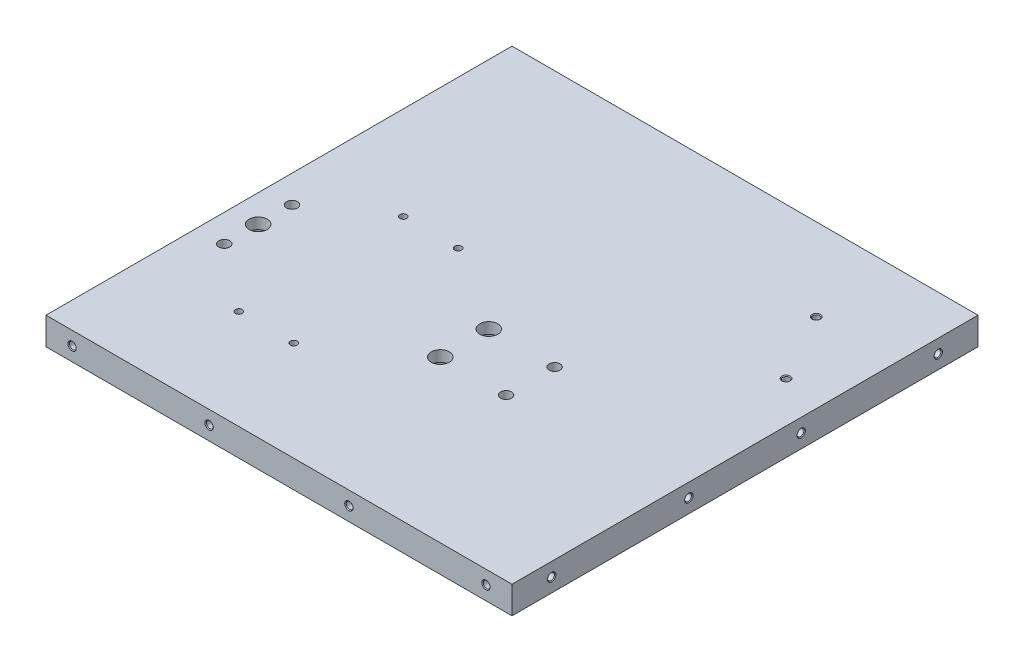
from build123d import *

# Parameters (mm, degrees)
SKETCH1_W                       = 170
SKETCH1_H                       = 170
BOSS_EXTRUDE1_DEPTH             = 10
F_4_0MM_DOWEL_HOLE1_D           = 4
F_4_0MM_DOWEL_HOLE1_DEPTH       = 5.2
F_4_0MM_DOWEL_HOLE1_TIP         = 1.201721238
CBORE_FOR_M6_SHCS1_D            = 6.6
CBORE_FOR_M6_SHCS1_DEPTH        = 10
CBORE_FOR_M6_SHCS1_CBORE_D      = 11
CBORE_FOR_M6_SHCS1_CBORE_DEPTH  = 6
M3X0_5_TAPPED_HOLE1_D           = 2.5
M3X0_5_TAPPED_HOLE1_DEPTH       = 7.5
M3X0_5_TAPPED_HOLE1_TIP         = 0.751075774
M3X0_5_TAPPED_HOLE2_D           = 2.5
M3X0_5_TAPPED_HOLE2_DEPTH       = 10
M3X0_5_TAPPED_HOLE2_CSINK_D     = 3.05
M3X0_5_TAPPED_HOLE2_CSINK_ANGLE = 90
M3X0_5_TAPPED_HOLE2_TIP         = 0.751075774
M3X0_5_TAPPED_HOLE3_D           = 2.5
M3X0_5_TAPPED_HOLE3_DEPTH       = 10
M3X0_5_TAPPED_HOLE3_CSINK_D     = 3.05
M3X0_5_TAPPED_HOLE3_CSINK_ANGLE = 90
M3X0_5_TAPPED_HOLE3_TIP         = 0.751075774
M3X0_5_TAPPED_HOLE4_D           = 2.5
M3X0_5_TAPPED_HOLE4_DEPTH       = 10
M3X0_5_TAPPED_HOLE4_CSINK_D     = 3.05
M3X0_5_TAPPED_HOLE4_CSINK_ANGLE = 90
M3X0_5_TAPPED_HOLE4_TIP         = 0.751075774
M3X0_5_TAPPED_HOLE5_D           = 2.5
M3X0_5_TAPPED_HOLE5_DEPTH       = 10
M3X0_5_TAPPED_HOLE5_CSINK_D     = 3.05
M3X0_5_TAPPED_HOLE5_CSINK_ANGLE = 90
M3X0_5_TAPPED_HOLE5_TIP         = 0.751075774
M3X0_5_TAPPED_HOLE6_D           = 2.5
M3X0_5_TAPPED_HOLE6_DEPTH       = 8
M3X0_5_TAPPED_HOLE6_CSINK_D     = 3.05
M3X0_5_TAPPED_HOLE6_CSINK_ANGLE = 90
M3X0_5_TAPPED_HOLE6_TIP         = 0.751075774


with BuildPart() as part:
    # Sketch1 → Boss-Extrude1 (new body)
    with BuildSketch(Plane(origin=(0, 0, 0), x_dir=(1, 0, 0), z_dir=(0, 1, 0))):
        with Locations((-21.335769449, -13.148097821)):
            Rectangle(SKETCH1_W, SKETCH1_H)
    extrude(amount=BOSS_EXTRUDE1_DEPTH)

    # Ø4.0mm Dowel Hole1
    with Locations(Plane(origin=(0, 10, 0), x_dir=(1, 0, 0), z_dir=(0, 1, 0))):
        with Locations((2.809433667, -21.75635539), (2.809433667, -39.45635539), (-96.335769449, -18.40635539), (-96.335769449, -43.10635539)):
            Hole(F_4_0MM_DOWEL_HOLE1_D / 2, depth=F_4_0MM_DOWEL_HOLE1_DEPTH)
            with Locations((0, 0, -(F_4_0MM_DOWEL_HOLE1_DEPTH + F_4_0MM_DOWEL_HOLE1_TIP / 2))):  # 118° drill point
                Cone(0, F_4_0MM_DOWEL_HOLE1_D / 2, F_4_0MM_DOWEL_HOLE1_TIP, mode=Mode.SUBTRACT)

    # CBORE for M6 SHCS1
    with Locations(Plane(origin=(0, 0, 0), x_dir=(-1, 0, 0), z_dir=(0, -1, 0))):
        with Locations((96.335769449, -30.75635539), (21.190566333, -39.45635539), (21.190566333, -21.75635539)):
            CounterBoreHole(CBORE_FOR_M6_SHCS1_D / 2, CBORE_FOR_M6_SHCS1_CBORE_D / 2, CBORE_FOR_M6_SHCS1_CBORE_DEPTH, depth=CBORE_FOR_M6_SHCS1_DEPTH)

    # M3x0.5 Tapped Hole1
    with Locations(Plane(origin=(0, 10, 0), x_dir=(1, 0, 0), z_dir=(0, 1, 0))):
        with Locations((-72.324091559, -61.794513309), (-52.324091559, -61.794513309), (-72.324091559, -1.794513309), (-52.324091559, -1.794513309)):
            Hole(M3X0_5_TAPPED_HOLE1_D / 2, depth=M3X0_5_TAPPED_HOLE1_DEPTH)
            with Locations((0, 0, -(M3X0_5_TAPPED_HOLE1_DEPTH + M3X0_5_TAPPED_HOLE1_TIP / 2))):  # 118° drill point
                Cone(0, M3X0_5_TAPPED_HOLE1_D / 2, M3X0_5_TAPPED_HOLE1_TIP, mode=Mode.SUBTRACT)

    # M3x0.5 Tapped Hole2
    with Locations(Plane.XY.offset(98.148097821)):
        with Locations((-96.835769449, 5), (-46.835769449, 5), (4.164230551, 5), (54.164230551, 5)):
            CounterSinkHole(M3X0_5_TAPPED_HOLE2_D / 2, M3X0_5_TAPPED_HOLE2_CSINK_D / 2, depth=M3X0_5_TAPPED_HOLE2_DEPTH, counter_sink_angle=M3X0_5_TAPPED_HOLE2_CSINK_ANGLE)
            with Locations((0, 0, -(M3X0_5_TAPPED_HOLE2_DEPTH + M3X0_5_TAPPED_HOLE2_TIP / 2))):  # 118° drill point
                Cone(0, M3X0_5_TAPPED_HOLE2_D / 2, M3X0_5_TAPPED_HOLE2_TIP, mode=Mode.SUBTRACT)

    # M3x0.5 Tapped Hole3
    with Locations(Plane.ZY.offset(106.335769449)):
        with Locations((-60.851902179, 5), (-10.851902179, 5), (37.148097821, 5), (87.148097821, 5)):
            CounterSinkHole(M3X0_5_TAPPED_HOLE3_D / 2, M3X0_5_TAPPED_HOLE3_CSINK_D / 2, depth=M3X0_5_TAPPED_HOLE3_DEPTH, counter_sink_angle=M3X0_5_TAPPED_HOLE3_CSINK_ANGLE)
            with Locations((0, 0, -(M3X0_5_TAPPED_HOLE3_DEPTH + M3X0_5_TAPPED_HOLE3_TIP / 2))):  # 118° drill point
                Cone(0, M3X0_5_TAPPED_HOLE3_D / 2, M3X0_5_TAPPED_HOLE3_TIP, mode=Mode.SUBTRACT)

    # M3x0.5 Tapped Hole4
    with Locations(Plane(origin=(0, 0, -71.851902179), x_dir=(-1, 0, 0), z_dir=(0, 0, -1))):
        with Locations((-54.164230551, 5), (-4.164230551, 5), (46.835769449, 5), (96.835769449, 5)):
            CounterSinkHole(M3X0_5_TAPPED_HOLE4_D / 2, M3X0_5_TAPPED_HOLE4_CSINK_D / 2, depth=M3X0_5_TAPPED_HOLE4_DEPTH, counter_sink_angle=M3X0_5_TAPPED_HOLE4_CSINK_ANGLE)
            with Locations((0, 0, -(M3X0_5_TAPPED_HOLE4_DEPTH + M3X0_5_TAPPED_HOLE4_TIP / 2))):  # 118° drill point
                Cone(0, M3X0_5_TAPPED_HOLE4_D / 2, M3X0_5_TAPPED_HOLE4_TIP, mode=Mode.SUBTRACT)

    # M3x0.5 Tapped Hole5
    with Locations(Plane(origin=(63.664230551, 0, 0), x_dir=(0, 0, -1), z_dir=(1, 0, 0))):
        with Locations((-83.648097821, 5), (-33.648097821, 5), (7.351902179, 5), (57.351902179, 5)):
            CounterSinkHole(M3X0_5_TAPPED_HOLE5_D / 2, M3X0_5_TAPPED_HOLE5_CSINK_D / 2, depth=M3X0_5_TAPPED_HOLE5_DEPTH, counter_sink_angle=M3X0_5_TAPPED_HOLE5_CSINK_ANGLE)
            with Locations((0, 0, -(M3X0_5_TAPPED_HOLE5_DEPTH + M3X0_5_TAPPED_HOLE5_TIP / 2))):  # 118° drill point
                Cone(0, M3X0_5_TAPPED_HOLE5_D / 2, M3X0_5_TAPPED_HOLE5_TIP, mode=Mode.SUBTRACT)

    # M3x0.5 Tapped Hole6
    with Locations(Plane(origin=(0, 10, 0), x_dir=(1, 0, 0), z_dir=(0, 1, 0))):
        with Locations((34.664230551, 41.851902179), (48.664230551, 16.851902179)):
            CounterSinkHole(M3X0_5_TAPPED_HOLE6_D / 2, M3X0_5_TAPPED_HOLE6_CSINK_D / 2, depth=M3X0_5_TAPPED_HOLE6_DEPTH, counter_sink_angle=M3X0_5_TAPPED_HOLE6_CSINK_ANGLE)
            with Locations((0, 0, -(M3X0_5_TAPPED_HOLE6_DEPTH + M3X0_5_TAPPED_HOLE6_TIP / 2))):  # 118° drill point
                Cone(0, M3X0_5_TAPPED_HOLE6_D / 2, M3X0_5_TAPPED_HOLE6_TIP, mode=Mode.SUBTRACT)


solid = part.part
